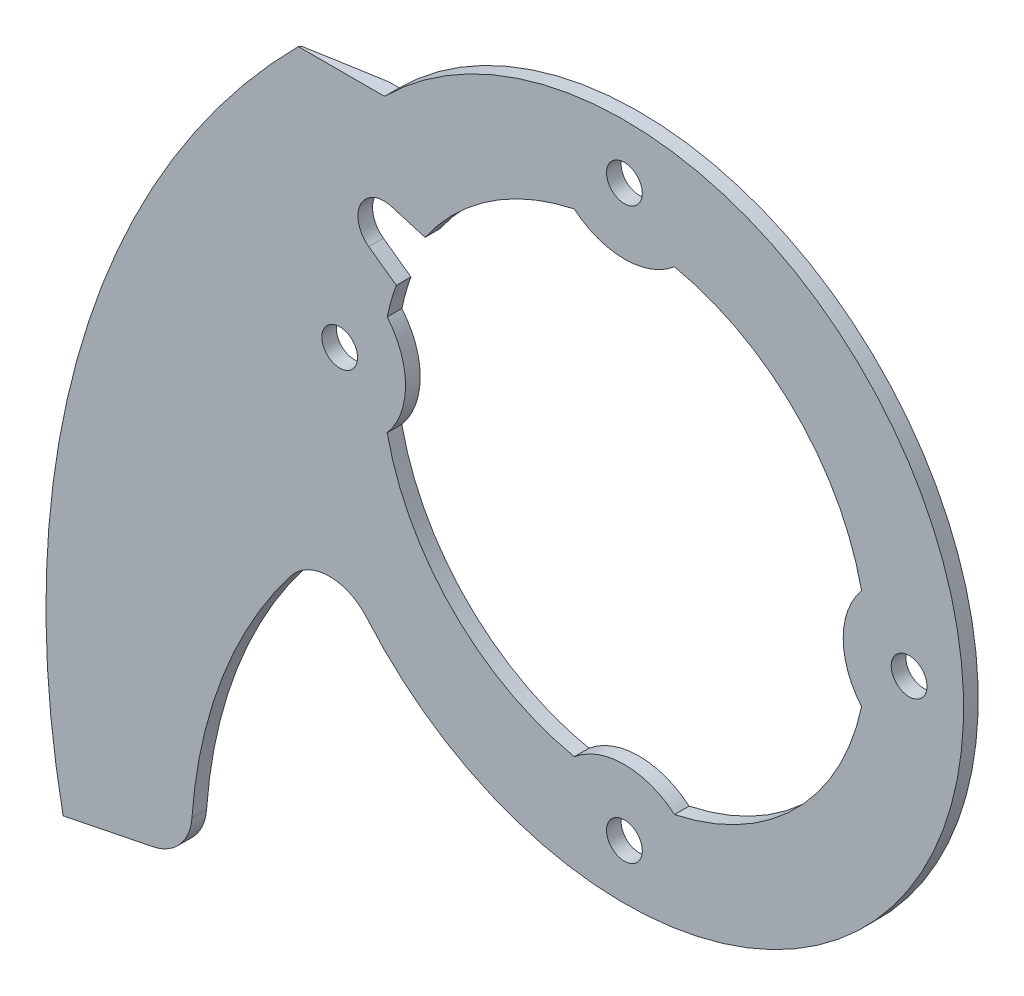
from build123d import *

# Parameters (mm, degrees)
TOP_BLADE_PROFILE_R     = 1.1
BASIC_BLADE_SHAPE_DEPTH = 0.9
EDGE_GRIND_SIZE         = 0.072
EDGE_GRIND_SIZE2        = 0.098954535
BLADE_ROOT_FILLET_R     = 3
BLADE_END_FILLET_R      = 3


with BuildPart() as part:
    # top blade profile → basic blade shape (new body)
    with BuildSketch(Plane.XY):
        with BuildLine():
            Line((-14.743176388, 14.743176388), (-20.043176388, 14.743176388))
            ThreePointArc((-20.043176388, 14.743176388), (-33.304536559, -7.535711071), (-34.497327018, -33.435320159))
            Line((-34.497327018, -33.435320159), (-26.655881065, -31.850477781))
            ThreePointArc((-26.655881065, -31.850477781), (-24.405908014, -20.396982829), (-17.885844028, -10.715366695))
            ThreePointArc((-17.885844028, -10.715366695), (-11.75653181, -17.219362932), (-3.467222551, -20.559690362))
            ThreePointArc((-3.467222551, -20.559690362), (20.559690362, -3.467222551), (3.467222551, 20.559690362))
            ThreePointArc((3.467222551, 20.559690362), (-6.343874402, 19.861464135), (-14.743176388, 14.743176388))
        make_face()
        with Locations((-17.5, 0)):
            Circle(TOP_BLADE_PROFILE_R, mode=Mode.SUBTRACT)
        with Locations((0, -17.5)):
            Circle(TOP_BLADE_PROFILE_R, mode=Mode.SUBTRACT)
        with Locations((17.5, 0)):
            Circle(TOP_BLADE_PROFILE_R, mode=Mode.SUBTRACT)
        with Locations((0, 17.5)):
            Circle(TOP_BLADE_PROFILE_R, mode=Mode.SUBTRACT)
        with BuildLine():
            Line((-15.713707666, 6.258524906), (-14.021091263, 5.041725875))
            ThreePointArc((-14.021091263, 5.041725875), (-14.333173834, 4.07064219), (-14.578087267, 3.080482372))
            ThreePointArc((-14.578087267, 3.080482372), (-13.45, 0), (-14.578087267, -3.080482372))
            ThreePointArc((-14.578087267, -3.080482372), (-10.53589104, -10.53589104), (-3.080482372, -14.578087267))
            ThreePointArc((-3.080482372, -14.578087267), (0, -13.45), (3.080482372, -14.578087267))
            ThreePointArc((3.080482372, -14.578087267), (10.53589104, -10.53589104), (14.578087267, -3.080482372))
            ThreePointArc((14.578087267, -3.080482372), (13.45, 0), (14.578087267, 3.080482372))
            ThreePointArc((14.578087267, 3.080482372), (10.53589104, 10.53589104), (3.080482372, 14.578087267))
            ThreePointArc((3.080482372, 14.578087267), (0, 13.45), (-3.080482372, 14.578087267))
            ThreePointArc((-3.080482372, 14.578087267), (-8.250663905, 12.407116713), (-12.252281094, 8.478891908))
            Line((-12.252281094, 8.478891908), (-14.32615504, 9.092015713))
            ThreePointArc((-14.32615504, 9.092015713), (-16.216729433, 8.261339025), (-15.713707666, 6.258524906))
        make_face(mode=Mode.SUBTRACT)
    extrude(amount=BASIC_BLADE_SHAPE_DEPTH)

    # blade grind: sweep along a path in grind path
    with BuildLine(Plane.XY.offset(0.9)) as blade_grind_path:
        ThreePointArc((-14.282047318, 19.76313332), (-32.075420619, -3.915533869), (-34.497327018, -33.435320159))
    # Sketch1 → blade grind (sweep, cut)
    with BuildSketch(Plane(origin=(5.138564907, -25.424470933, 0), x_dir=(0.9801807441283484, 0.19810529735470822, 0), z_dir=(0.19810529735470822, -0.9801807441283484, 0))):
        Polygon((-40.43732971, 0), (-40.43732971, 0.8), (-37.23732971, 0), align=None)
    sweep(path=blade_grind_path.line, mode=Mode.SUBTRACT)

    # edge grind
    edge_grind_edges = [part.edges().sort_by_distance(p)[0] for p in [
        (-33.304536559, -7.535711071, 0.8),
    ]]
    edge_grind_side = [part.faces().sort_by_distance(p)[0] for p in [
        (-31.257621093, -6.37778083, 0.4),
    ]]
    chamfer(edge_grind_edges, length=EDGE_GRIND_SIZE, length2=EDGE_GRIND_SIZE2, reference=edge_grind_side[0])

    # blade root fillet
    blade_root_fillet_edges = [part.edges().sort_by_distance(p)[0] for p in [
        (-17.885844028, -10.715366695, 0.45),
    ]]
    fillet(blade_root_fillet_edges, radius=BLADE_ROOT_FILLET_R)

    # blade end fillet
    blade_end_fillet_edges = [part.edges().sort_by_distance(p)[0] for p in [
        (-26.655881065, -31.850477781, 0.45),
    ]]
    fillet(blade_end_fillet_edges, radius=BLADE_END_FILLET_R)


solid = part.part
